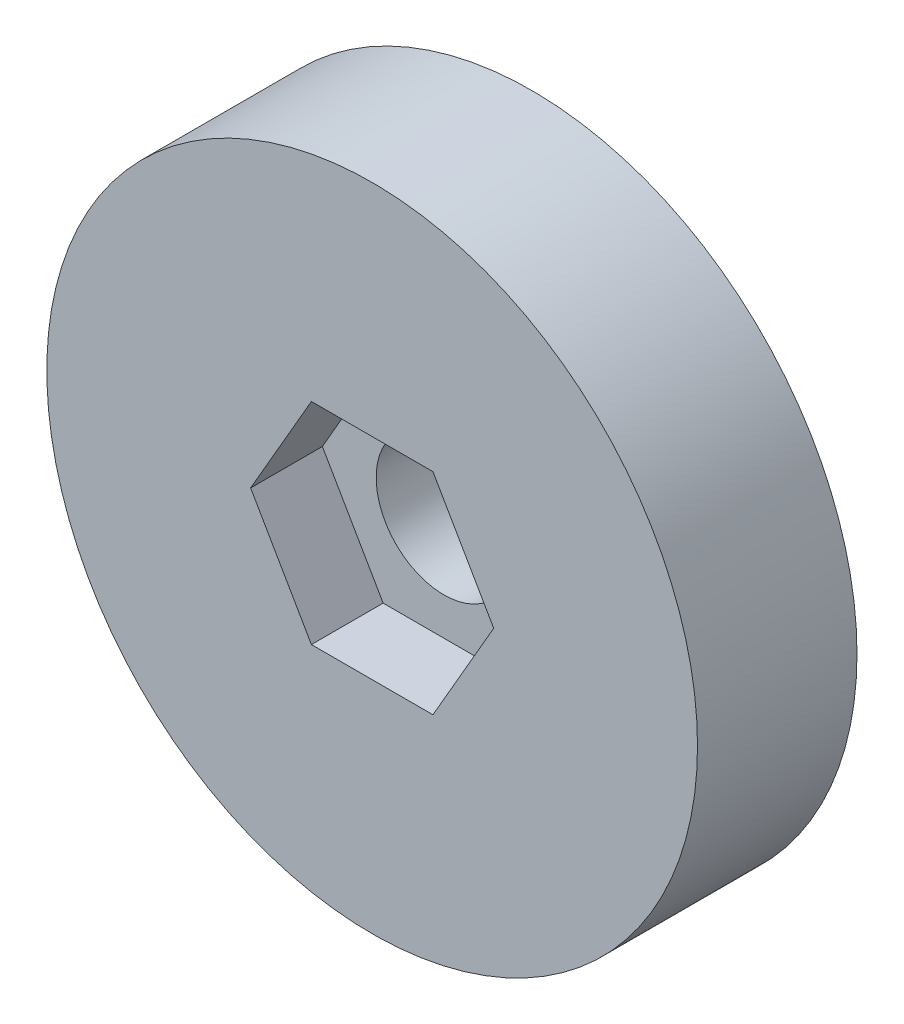
from build123d import *

# Parameters (mm, degrees)
ESBO_O1_R                = 20.4
ESBO_O1_R_2              = 4.25
RESSALTO_EXTRUS_O1_DEPTH = 10
CORTE_EXTRUS_O1_DEPTH    = 4.5


with BuildPart() as part:
    # Esboço1 → Ressalto-extrusão1 (new body)
    with BuildSketch(Plane.XY):
        Circle(ESBO_O1_R)
        Circle(ESBO_O1_R_2, mode=Mode.SUBTRACT)
    extrude(amount=RESSALTO_EXTRUS_O1_DEPTH)

    # Esboço2 → Corte-extrusão1 (cut)
    with BuildSketch(Plane.XY.offset(10)):
        Polygon((3.810511777, -6.6), (7.621023553, 0), (3.810511777, 6.6), (-3.810511777, 6.6), (-7.621023553, 0), (-3.810511777, -6.6), align=None)
    extrude(amount=-CORTE_EXTRUS_O1_DEPTH, mode=Mode.SUBTRACT)


solid = part.part
